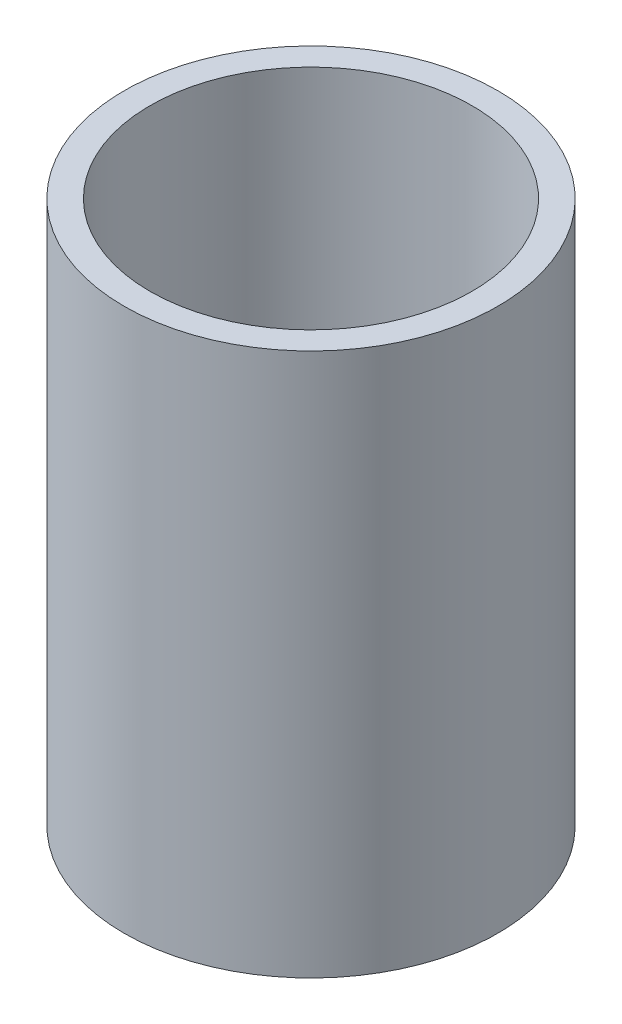
from build123d import *

# Parameters (mm, degrees)
SKETCH1_W = 6.35
SKETCH1_H = 133.35


with BuildPart() as part:
    # Sketch1 → Revolve1 (revolve)
    with BuildSketch(Plane.XY):
        with Locations((-42.6974, -21.057365567)):
            Rectangle(SKETCH1_W, SKETCH1_H)
    revolve(axis=Axis((0, 55, 0), (0, -1, 0)))


solid = part.part
